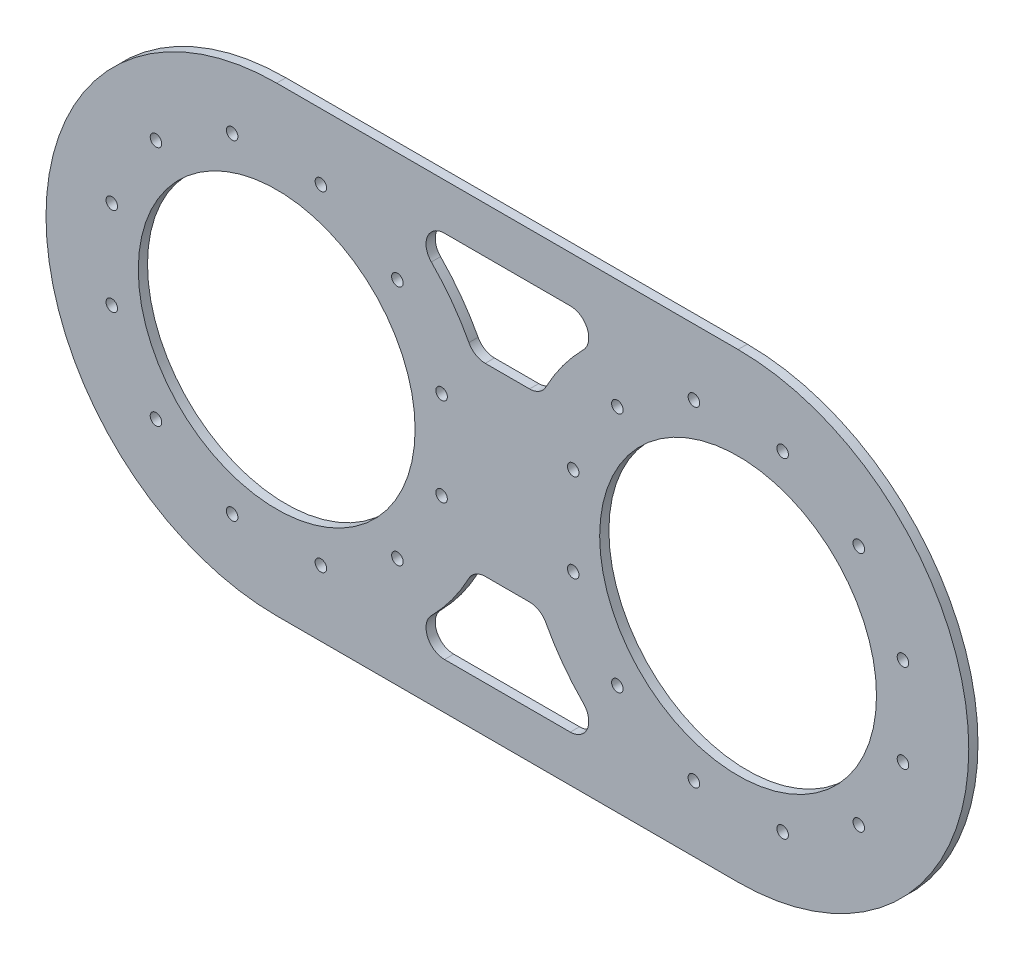
from build123d import *

# Parameters (mm, degrees)
SKETCH_1_R         = 30
EXTRUDE_1_DEPTH    = 2
HOLE_WIZARD_M3_1_D = 2.5
FILLET_1_R         = 4


with BuildPart() as part:
    # 草图1 → 凸台-拉伸1 (new body)
    with BuildSketch(Plane.XY):
        with BuildLine():
            Line((-50, 50), (-25, 50))
            Line((-25, 50), (25, 50))
            Line((25, 50), (50, 50))
            ThreePointArc((50, 50), (100, 0), (50, -50))
            Line((50, -50), (25, -50))
            Line((25, -50), (-25, -50))
            Line((-25, -50), (-50, -50))
            ThreePointArc((-50, -50), (-100, 0), (-50, 50))
        make_face()
        with Locations((-50, 0)):
            Circle(SKETCH_1_R, mode=Mode.SUBTRACT)
        with Locations((50, 0)):
            Circle(SKETCH_1_R, mode=Mode.SUBTRACT)
        with BuildLine():
            Line((-7.279981273, -20), (7.279981273, -20))
            ThreePointArc((7.279981273, -20), (14.694189797, -31.280980898), (25, -40))
            Line((25, -40), (-25, -40))
            ThreePointArc((-25, -40), (-14.694189797, -31.280980898), (-7.279981273, -20))
        make_face(mode=Mode.SUBTRACT)
        with BuildLine():
            Line((25, 40), (-25, 40))
            ThreePointArc((-25, 40), (-14.694189797, 31.280980898), (-7.279981273, 20))
            Line((-7.279981273, 20), (7.279981273, 20))
            ThreePointArc((7.279981273, 20), (14.694189797, 31.280980898), (25, 40))
        make_face(mode=Mode.SUBTRACT)
    extrude(amount=EXTRUDE_1_DEPTH)

    # M3 螺纹孔的螺纹孔钻头1 (through all)
    with Locations(Plane(origin=(-40.423695331, 35.739255573, 2), x_dir=(1, 0, 0), z_dir=(0, 0, 1))):
        with Locations((0, 0), (16.586646235, -9.576304669), (26.162950904, -26.162950904), (-19.23309471, -0.021663184), (-35.739255573, -9.576304669), (-45.315560242, -26.162950904), (126.162950904, -26.162950904), (116.586646235, -9.576304669), (100.080485372, -0.021663184), (54.684439758, -26.162950904), (64.260744427, -9.576304669), (80.847390662, 0), (80.847390662, -71.478511146), (64.260744427, -61.902206477), (54.684439758, -45.315560242), (100.080485372, -71.456847962), (116.586646235, -61.902206477), (126.162950904, -45.315560242), (-45.315560242, -45.315560242), (-35.739255573, -61.902206477), (-19.23309471, -71.456847962), (26.162950904, -45.315560242), (16.586646235, -61.902206477), (0, -71.478511146)):
            Hole(HOLE_WIZARD_M3_1_D / 2)

    # 圆角1
    fillet_1_edges = [part.edges().sort_by_distance(p)[0] for p in [
        (-7.279981273, -20, 1),
        (-25, -40, 1),
        (25, -40, 1),
        (7.279981273, -20, 1),
        (7.279981273, 20, 1),
        (25, 40, 1),
        (-25, 40, 1),
        (-7.279981273, 20, 1),
    ]]
    fillet(fillet_1_edges, radius=FILLET_1_R)


solid = part.part
